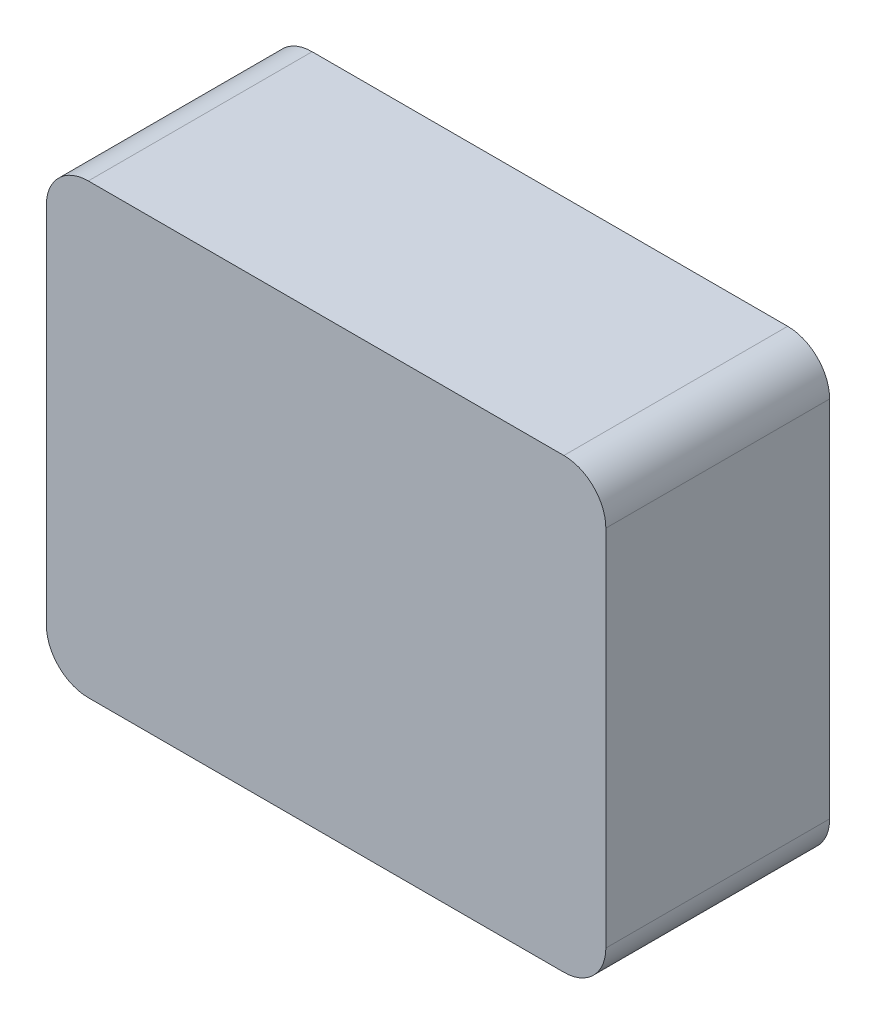
from build123d import *

# Parameters (mm, degrees)
SKETCH1_W      = 127
SKETCH1_H      = 101.6
EXTRUDE1_DEPTH = 50.8
FILLET1_R      = 9.525


with BuildPart() as part:
    # Sketch1 → Extrude1 (new body)
    with BuildSketch(Plane.XY):
        with Locations((63.5, 50.8)):
            Rectangle(SKETCH1_W, SKETCH1_H)
    extrude(amount=EXTRUDE1_DEPTH)

    # Fillet1
    fillet1_edges = [part.edges().sort_by_distance(p)[0] for p in [
        (0, 0, 25.4),
        (127, 0, 25.4),
        (127, 101.6, 25.4),
        (0, 101.6, 25.4),
    ]]
    fillet(fillet1_edges, radius=FILLET1_R)


solid = part.part
